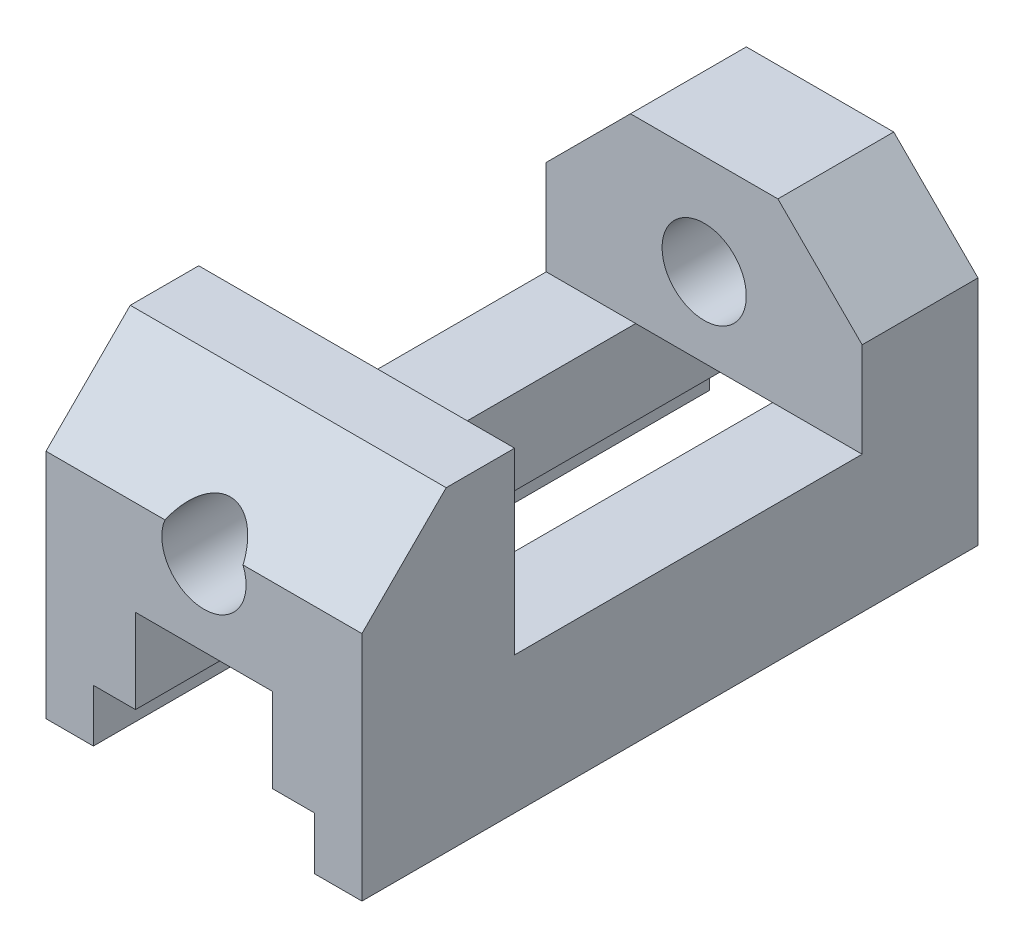
from build123d import *

# Parameters (mm, degrees)
SKETCH1_R               = 8
BOSS_EXTRUDE1_DEPTH     = 117
SKETCH2_W               = 66
SKETCH2_H               = 34
CUT_EXTRUDE1_DEPTH      = 31
CUT_EXTRUDE1_DEPTH_BACK = 31
CUT_EXTRUDE2_DEPTH      = 22


with BuildPart() as part:
    # Sketch1 → Boss-Extrude1 (new body)
    with BuildSketch(Plane.XY):
        Polygon((30, 19), (-30, 19), (-30, -41), (-21, -41), (-21, -31), (-13, -31), (-13, -15), (13, -15), (13, -31), (21, -31), (21, -41), (30, -41), align=None)
        Circle(SKETCH1_R, mode=Mode.SUBTRACT)
    extrude(amount=BOSS_EXTRUDE1_DEPTH)

    # Sketch2 → Cut-Extrude1 (cut, two sides)
    with BuildSketch(Plane(origin=(0, 0, 0), x_dir=(0, 0, -1), z_dir=(1, 0, 0))) as cut_extrude1_sk:
        Polygon((-117, 3), (-101, 19), (-117, 19), align=None)
        with Locations((-55, 2)):
            Rectangle(SKETCH2_W, SKETCH2_H)
    extrude(amount=CUT_EXTRUDE1_DEPTH, mode=Mode.SUBTRACT)
    extrude(cut_extrude1_sk.sketch, amount=-CUT_EXTRUDE1_DEPTH_BACK, mode=Mode.SUBTRACT)

    # Sketch1_3 → Cut-Extrude2 (cut)
    with BuildSketch(Plane.XY):
        Polygon((30, 3), (30, 19), (14, 19), align=None)
        Polygon((-30, 3), (-14, 19), (-30, 19), align=None)
    extrude(amount=CUT_EXTRUDE2_DEPTH, mode=Mode.SUBTRACT)


solid = part.part
